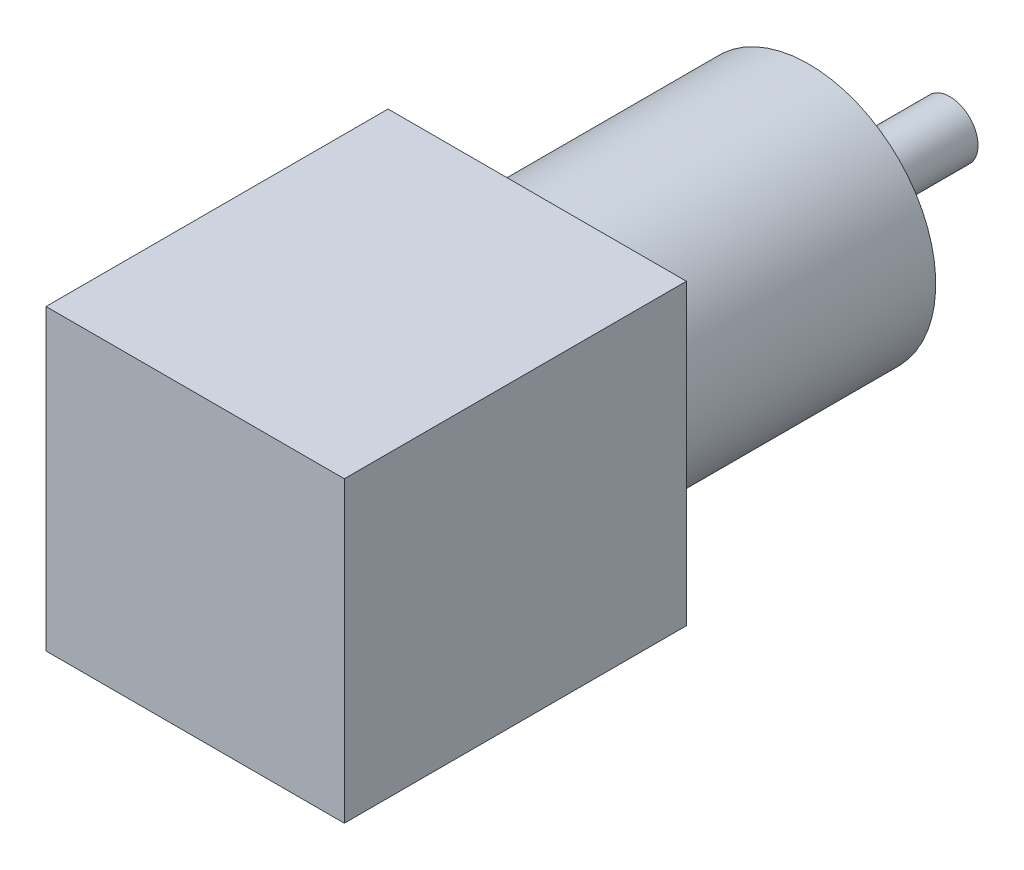
from build123d import *

# Parameters (mm, degrees)
SKETCH1_W           = 42.3
SKETCH1_H           = 42.3
BOSS_EXTRUDE1_DEPTH = 48.5
SKETCH3_R           = 18
BOSS_EXTRUDE2_DEPTH = 38.5
SKETCH5_R           = 4
BOSS_EXTRUDE3_DEPTH = 20
SKETCH6_R           = 1.5
CUT_EXTRUDE1_DEPTH  = 10


with BuildPart() as part:
    # Sketch1 → Boss-Extrude1 (new body)
    with BuildSketch(Plane.XY):
        Rectangle(SKETCH1_W, SKETCH1_H)
    extrude(amount=BOSS_EXTRUDE1_DEPTH)

    # Sketch3 → Boss-Extrude2 (add)
    with BuildSketch(Plane(origin=(0, 0, 0), x_dir=(-1, 0, 0), z_dir=(0, 0, -1))):
        Circle(SKETCH3_R)
    extrude(amount=BOSS_EXTRUDE2_DEPTH)

    # Sketch5 → Boss-Extrude3 (add)
    with BuildSketch(Plane(origin=(0, 0, -38.5), x_dir=(-1, 0, 0), z_dir=(0, 0, -1))):
        Circle(SKETCH5_R)
    extrude(amount=BOSS_EXTRUDE3_DEPTH)

    # Sketch6 → Cut-Extrude1 (cut)
    with BuildSketch(Plane(origin=(0, 0, -38.5), x_dir=(-1, 0, 0), z_dir=(0, 0, -1))):
        with Locations((-10.606601718, 10.606601718)):
            Circle(SKETCH6_R)
        with Locations((10.606601718, 10.606601718)):
            Circle(SKETCH6_R)
        with Locations((10.606601718, -10.606601718)):
            Circle(SKETCH6_R)
        with Locations((-10.606601718, -10.606601718)):
            Circle(SKETCH6_R)
    extrude(amount=-CUT_EXTRUDE1_DEPTH, mode=Mode.SUBTRACT)


solid = part.part
